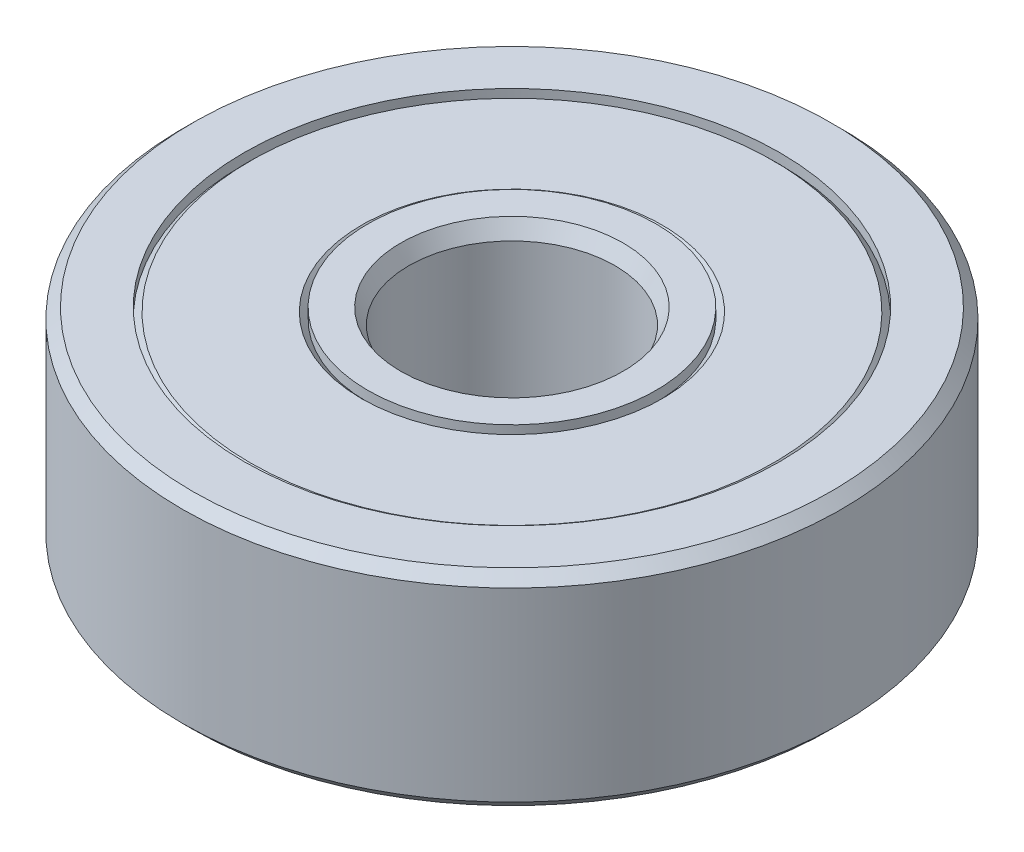
from build123d import *

# Parameters (mm, degrees)
SKETCH_1_R        = 3.5
SKETCH_1_R_2      = 2.5
EXTRUDE_1_DEPTH   = 5
SKETCH_1_R_3      = 8
SKETCH_1_R_4      = 6.5
EXTRUDE_1_2_DEPTH = 5
EXTRUDE_START     = 0.1
SKETCH_1_3_R      = 6.5
SKETCH_1_3_R_2    = 3.5
EXTRUDE_2_DEPTH   = 4.8
CHAMFER_1_SIZE    = 0.25
CHAMFER_2_SIZE    = 0.2
CHAMFER_2_SIZE2   = 0.376145293
CHAMFER_3_SIZE    = 0.15
CHAMFER_4_SIZE    = 0.2
CHAMFER_4_SIZE2   = 0.376145293


with BuildPart() as part:
    # Эскиз1 → Бобышка-Вытянуть1 (new body)
    with BuildSketch(Plane(origin=(0, 0, 0), x_dir=(1, 0, 0), z_dir=(0, 1, 0))):
        Circle(SKETCH_1_R)
        Circle(SKETCH_1_R_2, mode=Mode.SUBTRACT)
    extrude(amount=EXTRUDE_1_DEPTH)

    # Фаска2
    chamfer_2_edges = [part.edges().sort_by_distance(p)[0] for p in [
        (-2.5, 5, 0),
    ]]
    chamfer_2_side = [part.faces().sort_by_distance(p)[0] for p in [
        (-3.401005051, 5, 0),
    ]]
    chamfer(chamfer_2_edges, length=CHAMFER_2_SIZE, length2=CHAMFER_2_SIZE2, reference=chamfer_2_side[0])

    # Фаска4
    chamfer_4_edges = [part.edges().sort_by_distance(p)[0] for p in [
        (-2.5, 0, 0),
    ]]
    chamfer_4_side = [part.faces().sort_by_distance(p)[0] for p in [
        (-3.401005051, 0, 0),
    ]]
    chamfer(chamfer_4_edges, length=CHAMFER_4_SIZE, length2=CHAMFER_4_SIZE2, reference=chamfer_4_side[0])


with BuildPart() as body_2:
    # Эскиз1 → Extrude 1 2 (new body)
    with BuildSketch(Plane(origin=(0, 0, 0), x_dir=(1, 0, 0), z_dir=(0, 1, 0))):
        Circle(SKETCH_1_R_3)
        Circle(SKETCH_1_R_4, mode=Mode.SUBTRACT)
    extrude(amount=EXTRUDE_1_2_DEPTH)

    # Фаска1
    chamfer_1_edges = [body_2.edges().sort_by_distance(p)[0] for p in [
        (-8, 0, 0),
        (-8, 5, 0),
    ]]
    chamfer(chamfer_1_edges, length=CHAMFER_1_SIZE)


with BuildPart() as body_3:
    # Эскиз1<3> → Бобышка-Вытянуть2 (new body)
    with BuildSketch(Plane(origin=(0, 0, 0), x_dir=(1, 0, 0), z_dir=(0, 1, 0)).offset(EXTRUDE_START)):
        Circle(SKETCH_1_3_R)
        Circle(SKETCH_1_3_R_2, mode=Mode.SUBTRACT)
    extrude(amount=EXTRUDE_2_DEPTH)

    # Фаска3
    chamfer_3_edges = [body_3.edges().sort_by_distance(p)[0] for p in [
        (-6.5, 4.9, 0),
        (-6.5, 0.1, 0),
        (-3.5, 0.1, 0),
        (-3.5, 4.9, 0),
    ]]
    chamfer(chamfer_3_edges, length=CHAMFER_3_SIZE)


solid = Compound([part.part, body_2.part, body_3.part])
